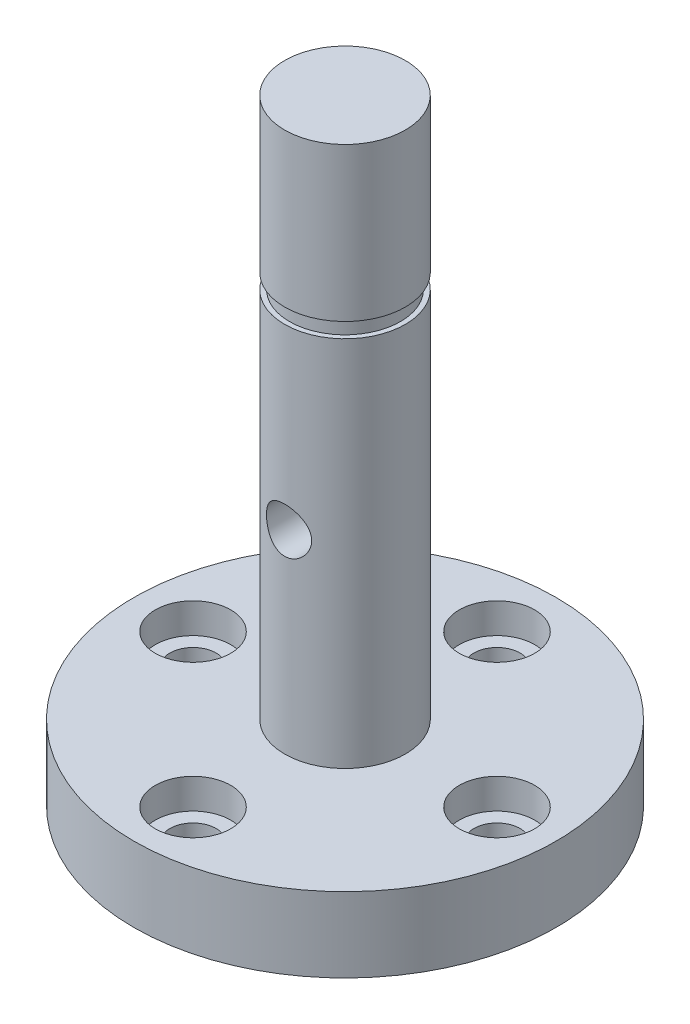
from build123d import *

# Parameters (mm, degrees)
SKETCH1_R                       = 11.1125
BOSS_EXTRUDE1_DEPTH             = 3.937
BOSS_EXTRUDE2_START             = -3.937
SKETCH2_R                       = 3.175
BOSS_EXTRUDE2_DEPTH             = 32.385
F_2_CLEARANCE_HOLE1_D           = 2.4384
SKETCH5_R                       = 1.984375
CUT_EXTRUDE1_DEPTH              = 1.5875
F_3_32_0_09375_DIAMETER_HOLE1_D = 2.38125
CUT_EXTRUDE2_START              = -8.85825
SKETCH9_R                       = 3.175
SKETCH9_R_2                     = 2.921
CUT_EXTRUDE2_DEPTH              = 0.7874


with BuildPart() as part:
    # Sketch1 → Boss-Extrude1 (new body)
    with BuildSketch(Plane(origin=(0, 0, 0), x_dir=(1, 0, 0), z_dir=(0, 1, 0))):
        Circle(SKETCH1_R)
    extrude(amount=BOSS_EXTRUDE1_DEPTH)

    # Sketch2 → Boss-Extrude2 (add)
    with BuildSketch(Plane(origin=(0, 3.937, 0), x_dir=(1, 0, 0), z_dir=(0, 1, 0)).offset(BOSS_EXTRUDE2_START)):
        Circle(SKETCH2_R)
    extrude(amount=BOSS_EXTRUDE2_DEPTH)

    # 2 Clearance Hole1 (through all)
    with Locations(Plane(origin=(0, 3.937, 0), x_dir=(1, 0, 0), z_dir=(0, 1, 0))):
        with Locations((0, -8), (0, 8), (-8, 0), (8, 0)):
            Hole(F_2_CLEARANCE_HOLE1_D / 2)

    # Sketch5 → Cut-Extrude1 (cut)
    with BuildSketch(Plane(origin=(0, 3.937, 0), x_dir=(1, 0, 0), z_dir=(0, 1, 0))):
        with Locations((0, -8)):
            Circle(SKETCH5_R)
        with Locations((8, 0)):
            Circle(SKETCH5_R)
        with Locations((0, 8)):
            Circle(SKETCH5_R)
        with Locations((-8, 0)):
            Circle(SKETCH5_R)
    extrude(amount=-CUT_EXTRUDE1_DEPTH, mode=Mode.SUBTRACT)

    # 3_32 _0.09375_ Diameter Hole1 (through all)
    with Locations(Plane.XY.offset(3.175)):
        with Locations((0, 14.144625)):
            Hole(F_3_32_0_09375_DIAMETER_HOLE1_D / 2)

    # Sketch9 → Cut-Extrude2 (cut)
    with BuildSketch(Plane(origin=(0, 32.385, 0), x_dir=(1, 0, 0), z_dir=(0, 1, 0)).offset(CUT_EXTRUDE2_START)):
        Circle(SKETCH9_R)
        Circle(SKETCH9_R_2, mode=Mode.SUBTRACT)
    extrude(amount=CUT_EXTRUDE2_DEPTH, mode=Mode.SUBTRACT)


solid = part.part
